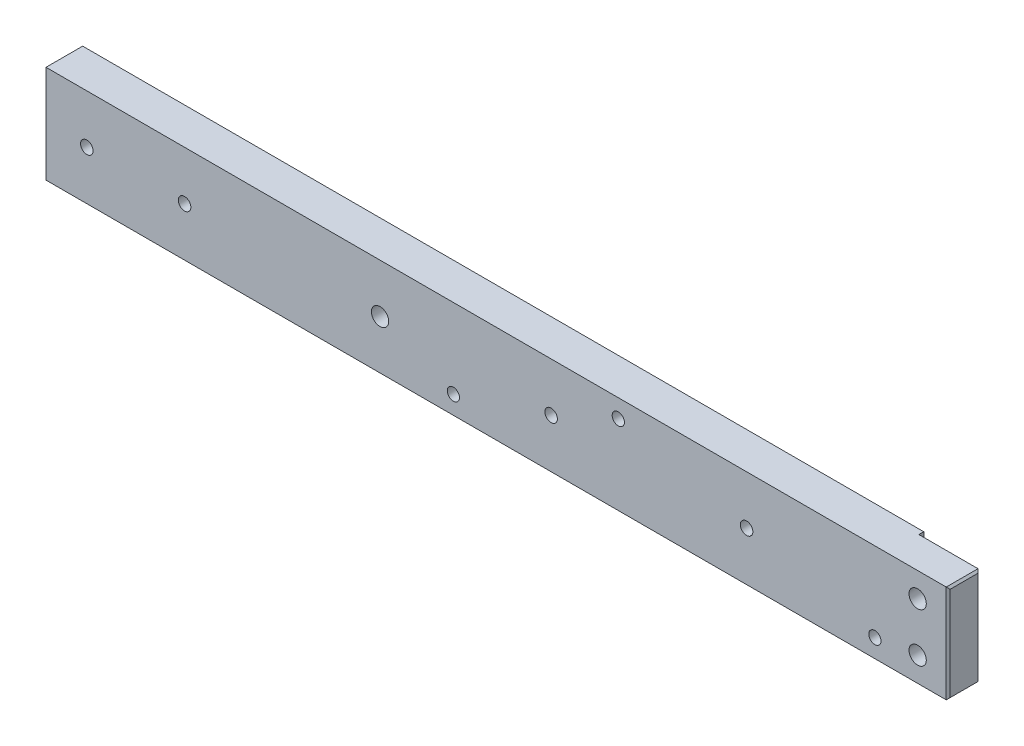
from build123d import *

# Parameters (mm, degrees)
SKETCH1_W                        = 234.95
SKETCH1_H                        = 25.4
BOSS_EXTRUDE1_DEPTH              = 9.525
F_8_CLEARANCE_HOLE1_D            = 4.4958
F_8_CLEARANCE_HOLE1_DEPTH        = 25.4
F_8_CLEARANCE_HOLE1_TIP          = 1.350674586
F_8_CLEARANCE_HOLE2_D            = 4.4958
F_8_CLEARANCE_HOLE2_DEPTH        = 19.05
F_8_CLEARANCE_HOLE2_TIP          = 1.350674586
F_4_CLEARANCE_HOLE3_D            = 3.2639
F_4_CLEARANCE_HOLE2_D            = 3.2639
F_4_CLEARANCE_HOLE2_DEPTH        = 9.525
F_1_8_0_125_DIAMETER_HOLE1_D     = 3.175
F_1_8_0_125_DIAMETER_HOLE1_DEPTH = 9.525
SKETCH18_W                       = 15.875
SKETCH18_H                       = 25.4
SKETCH18_R                       = 2.2479
CUT_EXTRUDE1_DEPTH               = 1.27
CHAMFER1_SIZE                    = 0.508


with BuildPart() as part:
    # Sketch1 → Boss-Extrude1 (new body)
    with BuildSketch(Plane.XY):
        with Locations((-117.475, 12.7)):
            Rectangle(SKETCH1_W, SKETCH1_H)
    extrude(amount=BOSS_EXTRUDE1_DEPTH)

    # #8 Clearance Hole1
    with Locations(Plane.XY.offset(9.525)):
        with Locations((-7.9375, 6.35), (-7.9375, 19.05)):
            Hole(F_8_CLEARANCE_HOLE1_D / 2, depth=F_8_CLEARANCE_HOLE1_DEPTH)
            with Locations((0, 0, -(F_8_CLEARANCE_HOLE1_DEPTH + F_8_CLEARANCE_HOLE1_TIP / 2))):  # 118° drill point
                Cone(0, F_8_CLEARANCE_HOLE1_D / 2, F_8_CLEARANCE_HOLE1_TIP, mode=Mode.SUBTRACT)

    # #8 Clearance Hole2
    with Locations(Plane.XY.offset(9.525)):
        with Locations((-147.6375, 12.7)):
            Hole(F_8_CLEARANCE_HOLE2_D / 2, depth=F_8_CLEARANCE_HOLE2_DEPTH)
            with Locations((0, 0, -(F_8_CLEARANCE_HOLE2_DEPTH + F_8_CLEARANCE_HOLE2_TIP / 2))):  # 118° drill point
                Cone(0, F_8_CLEARANCE_HOLE2_D / 2, F_8_CLEARANCE_HOLE2_TIP, mode=Mode.SUBTRACT)

    # #4 Clearance Hole3 (through all)
    with Locations(Plane(origin=(0, 0, 0), x_dir=(-1, 0, 0), z_dir=(0, 0, -1))):
        with Locations((103.1875, 12.7), (52.3875, 12.7)):
            Hole(F_4_CLEARANCE_HOLE3_D / 2)

    # #4 Clearance Hole2
    with Locations(Plane.XY.offset(9.525)):
        with Locations((-223.8375, 12.7), (-198.4375, 12.7)):
            Hole(F_4_CLEARANCE_HOLE2_D / 2, depth=F_4_CLEARANCE_HOLE2_DEPTH)

    # 1/8 (0.125) Diameter Hole1
    with Locations(Plane.XY.offset(9.525)):
        with Locations((-19.05, 4.7625), (-85.725, 20.6375), (-128.5875, 4.7625)):
            Hole(F_1_8_0_125_DIAMETER_HOLE1_D / 2, depth=F_1_8_0_125_DIAMETER_HOLE1_DEPTH)

    # Sketch18 → Cut-Extrude1 (cut)
    with BuildSketch(Plane(origin=(0, 0, 0), x_dir=(-1, 0, 0), z_dir=(0, 0, -1))):
        with Locations((7.9375, 12.7)):
            Rectangle(SKETCH18_W, SKETCH18_H)
        with Locations((7.9375, 6.35)):
            Circle(SKETCH18_R, mode=Mode.SUBTRACT)
    extrude(amount=-CUT_EXTRUDE1_DEPTH, mode=Mode.SUBTRACT)

    # Chamfer1
    chamfer1_edges = [part.edges().sort_by_distance(p)[0] for p in [
        (-234.95, 12.7, 9.525),
        (0, 12.7, 9.525),
        (-234.95, 12.7, 0),
        (0, 0, 5.3975),
        (-234.95, 0, 4.7625),
        (-234.95, 25.4, 4.7625),
        (0, 25.4, 5.3975),
        (0, 12.7, 1.27),
    ]]
    chamfer(chamfer1_edges, length=CHAMFER1_SIZE)


solid = part.part
